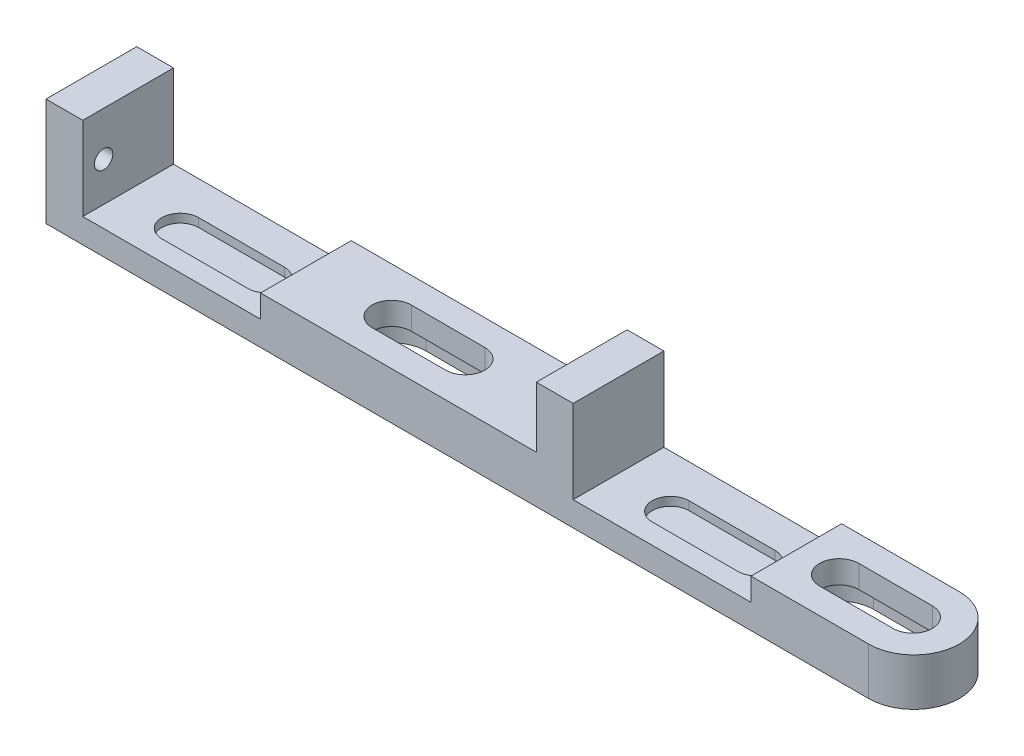
from build123d import *

# Parameters (mm, degrees)
BOSS_EXTRUDE1_DEPTH = 7.4
CUT_EXTRUDE1_DEPTH  = 10
CUT_EXTRUDE2_DEPTH  = 2
CUT_EXTRUDE3_REACH  = 72.8
SKETCH5_R           = 0.75
CUT_EXTRUDE4_DEPTH  = 10
CUT_EXTRUDE6_DEPTH  = 0.7


with BuildPart() as part:
    # Sketch1 → Boss-Extrude1 (new body)
    with BuildSketch(Plane.XY):
        Polygon((0, 0), (0, 8.8), (3, 8.8), (3, 2), (17.5, 2), (17.5, 3.85), (40, 3.85), (40, 8.8), (43, 8.8), (43, 2), (57.5, 2), (57.5, 3.85), (70.8, 3.85), (70.8, 0), align=None)
    extrude(amount=BOSS_EXTRUDE1_DEPTH)

    # Sketch3 → Cut-Extrude1 (cut)
    with BuildSketch(Plane(origin=(0, 3.85, 0), x_dir=(1, 0, 0), z_dir=(0, 1, 0))):
        with BuildLine():
            Line((30.5, -5.3), (24.5, -5.3))
            ThreePointArc((24.5, -5.3), (22.9, -3.7), (24.5, -2.1))
            Line((24.5, -2.1), (30.5, -2.1))
            ThreePointArc((30.5, -2.1), (32.1, -3.7), (30.5, -5.3))
        make_face()
        with BuildLine():
            Line((67, -5.3), (61, -5.3))
            ThreePointArc((61, -5.3), (59.4, -3.7), (61, -2.1))
            Line((61, -2.1), (67, -2.1))
            ThreePointArc((67, -2.1), (68.6, -3.7), (67, -5.3))
        make_face()
    extrude(amount=-CUT_EXTRUDE1_DEPTH, mode=Mode.SUBTRACT)

    # Sketch4 → Cut-Extrude2 (cut)
    with BuildSketch(Plane.XZ):
        with BuildLine():
            Line((24.5, 6.5), (30.5, 6.5))
            ThreePointArc((30.5, 6.5), (33.3, 3.7), (30.5, 0.9))
            Line((30.5, 0.9), (24.5, 0.9))
            ThreePointArc((24.5, 0.9), (21.7, 3.7), (24.5, 6.5))
        make_face()
        with BuildLine():
            Line((24.5, 5.3), (30.5, 5.3))
            ThreePointArc((30.5, 5.3), (32.1, 3.7), (30.5, 2.1))
            Line((30.5, 2.1), (24.5, 2.1))
            ThreePointArc((24.5, 2.1), (22.9, 3.7), (24.5, 5.3))
        make_face(mode=Mode.SUBTRACT)
        with BuildLine():
            Line((61, 6.5), (67, 6.5))
            ThreePointArc((67, 6.5), (69.8, 3.7), (67, 0.9))
            Line((67, 0.9), (61, 0.9))
            ThreePointArc((61, 0.9), (58.2, 3.7), (61, 6.5))
        make_face()
        with BuildLine():
            Line((61, 5.3), (67, 5.3))
            ThreePointArc((67, 5.3), (68.6, 3.7), (67, 2.1))
            Line((67, 2.1), (61, 2.1))
            ThreePointArc((61, 2.1), (59.4, 3.7), (61, 5.3))
        make_face(mode=Mode.SUBTRACT)
    extrude(amount=-CUT_EXTRUDE2_DEPTH, mode=Mode.SUBTRACT)

    # Sketch5 → Cut-Extrude3 (cut, up to next)
    with BuildSketch(Plane.ZY, mode=Mode.PRIVATE) as cut_extrude3_sk1:
        with Locations((5.7, 5.2)):
            Circle(SKETCH5_R)
    cut_extrude3_tool1 = extrude(cut_extrude3_sk1.sketch, amount=-CUT_EXTRUDE3_REACH, mode=Mode.PRIVATE) & part.part
    add(cut_extrude3_tool1.solids().sort_by_distance((0, 5.2, 5.7))[0], mode=Mode.SUBTRACT)

    # Sketch6 → Cut-Extrude4 (cut)
    with BuildSketch(Plane.XZ):
        with BuildLine():
            Line((67.1, 0), (70.8, 0))
            Line((70.8, 0), (70.8, 3.7))
            ThreePointArc((70.8, 3.7), (69.71629509, 1.08370491), (67.1, 0))
        make_face()
        with BuildLine():
            ThreePointArc((67.1, 7.4), (69.71629509, 6.31629509), (70.8, 3.7))
            Line((70.8, 3.7), (70.8, 7.4))
            Line((70.8, 7.4), (67.1, 7.4))
        make_face()
    extrude(amount=-CUT_EXTRUDE4_DEPTH, mode=Mode.SUBTRACT)

    # Sketch8 → Cut-Extrude6 (cut)
    with BuildSketch(Plane(origin=(0, 2, 0), x_dir=(1, 0, 0), z_dir=(0, 1, 0))):
        with BuildLine():
            Line((7.8, -2.75), (14.8, -2.75))
            ThreePointArc((14.8, -2.75), (16.3, -4.25), (14.8, -5.75))
            Line((14.8, -5.75), (7.8, -5.75))
            ThreePointArc((7.8, -5.75), (6.3, -4.25), (7.8, -2.75))
        make_face()
        with BuildLine():
            Line((47.8, -2.75), (54.8, -2.75))
            ThreePointArc((54.8, -2.75), (56.3, -4.25), (54.8, -5.75))
            Line((54.8, -5.75), (47.8, -5.75))
            ThreePointArc((47.8, -5.75), (46.3, -4.25), (47.8, -2.75))
        make_face()
    extrude(amount=-CUT_EXTRUDE6_DEPTH, mode=Mode.SUBTRACT)


solid = part.part
